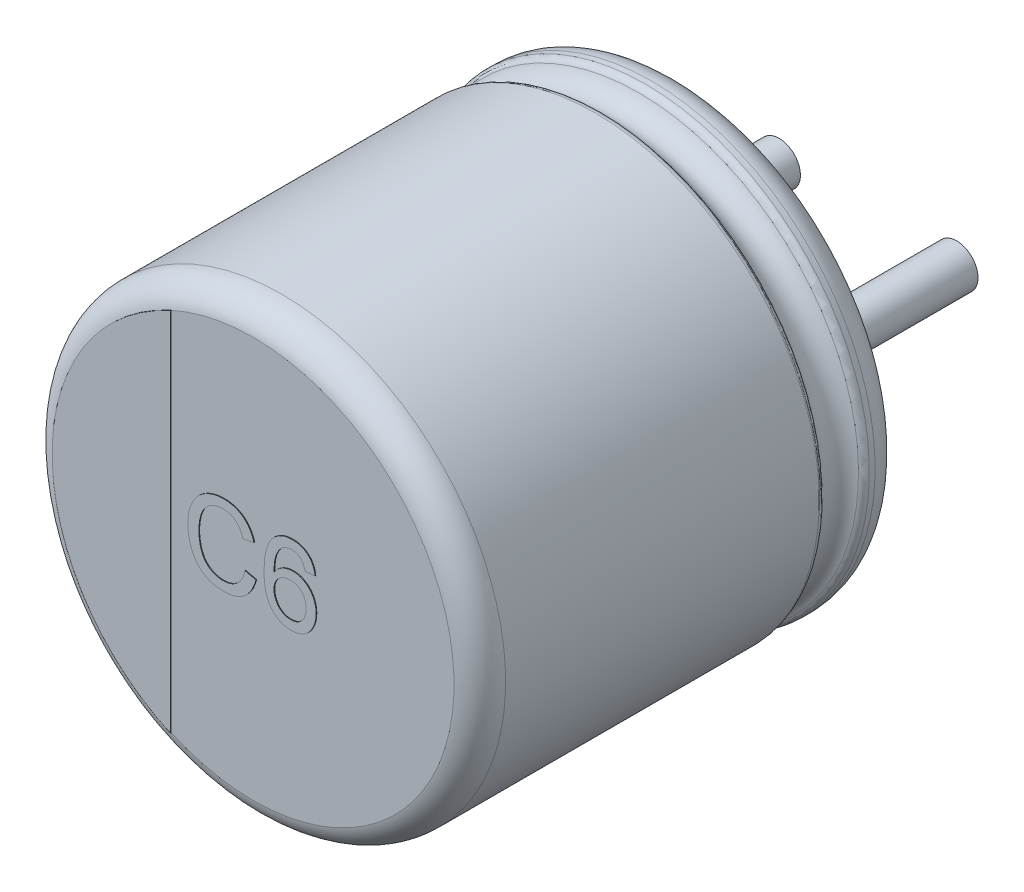
from build123d import *

# Parameters (mm, degrees)
SKETCH_2_R         = 0.3
EXTRUDE_1_DEPTH    = 2.7
EXTRUDE_2_DEPTH    = 0.01
EXTRUDE_1853_DEPTH = 0.01
EXTRUDE_5_DEPTH    = 0.05


with BuildPart() as part:
    # Sketch10 → Повернуть1 (revolve)
    with BuildSketch(Plane(origin=(0, 0, 0), x_dir=(0, 0, -1), z_dir=(1, 0, 0))):
        with BuildLine():
            Line((-6, 0), (-0.05, 0))
            Line((-0.05, 0), (-0.05, 2.553143426))
            ThreePointArc((-0.05, 2.553143426), (-0.052704561, 2.951565585), (-0.398206102, 3.15))
            Line((-0.398206102, 3.15), (-0.479422929, 3.15))
            ThreePointArc((-0.479422929, 3.15), (-0.534479696, 3.133479053), (-0.571344666, 3.089375046))
            ThreePointArc((-0.571344666, 3.089375046), (-0.831990181, 2.917472047), (-1.092635697, 3.089375046))
            ThreePointArc((-1.092635697, 3.089375046), (-1.129500666, 3.133479053), (-1.184557434, 3.15))
            Line((-1.184557434, 3.15), (-5.6, 3.15))
            ThreePointArc((-5.6, 3.15), (-5.85971595, 3.059961924), (-6, 2.82357323))
            Line((-6, 2.82357323), (-6, 0))
        make_face()
    revolve(axis=Axis((0, 0, -18.1630778), (0, 0, 1)))

    # Эскиз2 → Бобышка-Вытянуть1 (add)
    with BuildSketch(Plane(origin=(0, 0, 0.05), x_dir=(-1, 0, 0), z_dir=(0, 0, -1))):
        with Locations(Location((-1.25, 0, 0), (0, 0, 90))):
            Circle(SKETCH_2_R)
        with Locations(Location((1.25, 0, 0), (0, 0, 270))):
            Circle(SKETCH_2_R)
    extrude(amount=EXTRUDE_1_DEPTH)

    # Эскиз4 → Бобышка-Вытянуть2 (add)
    with BuildSketch(Plane.XY.offset(6)):
        with BuildLine():
            Line((-1.160332513, -2.574139515), (-1.160332513, 2.574139515))
            ThreePointArc((-1.160332513, 2.574139515), (-2.82357323, 0), (-1.160332513, -2.574139515))
        make_face()
    extrude(amount=EXTRUDE_2_DEPTH)

    # Эскиз5 → Extrude 1853 (add)
    with BuildSketch(Plane.XY.offset(6)):
        with BuildLine():
            Line((-0.108912855, -0.069918347), (0.04621535, -0.106056167))
            add(Edge.make_bspline(
                [(0.04621535, -0.106056167), (0.042328955, -0.120595903), (0.034726685, -0.149037431), (0.019696074, -0.189740405), (0.002826055, -0.22793841), (-0.016292712, -0.263530826), (-0.037869483, -0.296313018), (-0.061332559, -0.326706301), (-0.08761128, -0.354073299), (-0.115741448, -0.379045627), (-0.145942088, -0.401071154), (-0.177849082, -0.420090601), (-0.2113082, -0.436272289), (-0.246454673, -0.449579116), (-0.283311287, -0.459593644), (-0.321688266, -0.466892819), (-0.361697515, -0.471388685), (-0.388969191, -0.471980579), (-0.402863176, -0.472282129)],
                knots=[0, 0, 0, 0, 1.145254194, 2.240259345, 3.299159039, 4.322497661, 5.312016644, 6.284080175, 7.241264552, 8.196044782, 9.144516039, 10.082428046, 11.020306713, 11.970622414, 12.939253955, 13.924100776, 14.94240044, 16, 16, 16, 16], degree=3))
            add(Edge.make_bspline(
                [(-0.402863176, -0.472282129), (-0.417118674, -0.472075022), (-0.445008416, -0.471669834), (-0.48586528, -0.468374144), (-0.524724169, -0.462658281), (-0.561512517, -0.454716909), (-0.596354147, -0.444897895), (-0.629104581, -0.432544706), (-0.659706455, -0.417746474), (-0.68841503, -0.40091706), (-0.715108371, -0.381798088), (-0.740393493, -0.360905526), (-0.763656558, -0.337664227), (-0.785479231, -0.312622937), (-0.805386205, -0.285451329), (-0.824109863, -0.25651854), (-0.840736314, -0.225314775), (-0.855881721, -0.192418552), (-0.869175168, -0.158148367), (-0.880935219, -0.12318115), (-0.890549703, -0.087447226), (-0.898827154, -0.051247288), (-0.904840321, -0.01427674), (-0.90961459, 0.023187027), (-0.912239578, 0.061373697), (-0.912584999, 0.087042498), (-0.912759009, 0.09997348)],
                knots=[0, 0, 0, 0, 1.180702053, 2.309949215, 3.392367133, 4.431746864, 5.425408375, 6.388154007, 7.326956194, 8.237882283, 9.141054626, 10.043899035, 10.951650021, 11.86168169, 12.792564695, 13.739356664, 14.713891418, 15.718426911, 16.737522708, 17.757217648, 18.772674716, 19.801476837, 20.831699174, 21.873853055, 22.928926693, 24, 24, 24, 24], degree=3))
            add(Edge.make_bspline(
                [(-0.912759009, 0.09997348), (-0.912510138, 0.113932996), (-0.912018432, 0.141513475), (-0.909242757, 0.182209272), (-0.904144849, 0.221485694), (-0.897065337, 0.259368577), (-0.888106922, 0.295888601), (-0.877048763, 0.331063557), (-0.864030746, 0.364848441), (-0.849092557, 0.397280506), (-0.83213495, 0.427997725), (-0.81366404, 0.457043765), (-0.793239225, 0.483941703), (-0.771466071, 0.509205432), (-0.747800778, 0.532414283), (-0.72231561, 0.553620827), (-0.695230442, 0.573018497), (-0.666549228, 0.590427213), (-0.636646863, 0.605702449), (-0.605967495, 0.619308236), (-0.574389099, 0.630460027), (-0.542162036, 0.639732294), (-0.509216926, 0.647113879), (-0.475476789, 0.652049968), (-0.4409728, 0.655266706), (-0.417707516, 0.655702651), (-0.405948112, 0.655922999)],
                knots=[0, 0, 0, 0, 1.185634383, 2.342514083, 3.462112933, 4.547331452, 5.613960142, 6.653690668, 7.676612054, 8.686959706, 9.683658101, 10.654407272, 11.607580201, 12.5494388, 13.484601218, 14.419076806, 15.362504069, 16.311442244, 17.265594461, 18.212500624, 19.159571152, 20.107257795, 21.059246075, 22.024387127, 23.001429356, 24, 24, 24, 24], degree=3))
            add(Edge.make_bspline(
                [(-0.405948112, 0.655922999), (-0.392790923, 0.655674993), (-0.366929166, 0.655187511), (-0.328981645, 0.651177881), (-0.292637827, 0.64446219), (-0.25774023, 0.635651838), (-0.224651675, 0.623588633), (-0.19301293, 0.609246868), (-0.163138738, 0.592016975), (-0.134796652, 0.572372462), (-0.108448038, 0.5502771), (-0.083724175, 0.526258741), (-0.061633171, 0.499717103), (-0.04130009, 0.471294538), (-0.023364678, 0.440596924), (-0.007167108, 0.407891911), (0.006762331, 0.372936375), (0.014215274, 0.348588877), (0.018010222, 0.336191429)],
                knots=[0, 0, 0, 0, 1.098391872, 2.158997981, 3.181470371, 4.182549255, 5.160268219, 6.118029851, 7.079534476, 8.035645336, 8.993622929, 9.94770573, 10.909620999, 11.872786677, 12.862530088, 13.874594564, 14.917769567, 16, 16, 16, 16], degree=3))
            Line((0.018010222, 0.336191429), (-0.137117984, 0.302918192))
            add(Edge.make_bspline(
                [(-0.137117984, 0.302918192), (-0.140164459, 0.312432596), (-0.146127355, 0.331055231), (-0.15671506, 0.357595794), (-0.168149428, 0.382234108), (-0.180702836, 0.404802692), (-0.194402488, 0.425306953), (-0.20893292, 0.443996089), (-0.224642265, 0.460521265), (-0.241210981, 0.47526351), (-0.259066923, 0.487822492), (-0.277791469, 0.498951816), (-0.297779426, 0.508159635), (-0.318743252, 0.515947548), (-0.340878894, 0.521874989), (-0.364096214, 0.526045177), (-0.388415609, 0.528458678), (-0.404987911, 0.528817113), (-0.413440099, 0.528999922)],
                knots=[0, 0, 0, 0, 1.235697765, 2.418642872, 3.532555292, 4.594392283, 5.610119701, 6.580908344, 7.519430642, 8.427315627, 9.319973334, 10.216139639, 11.118687699, 12.038725643, 12.980015607, 13.949697744, 14.954307006, 16, 16, 16, 16], degree=3))
            add(Edge.make_bspline(
                [(-0.413440099, 0.528999922), (-0.423143984, 0.528859129), (-0.442228662, 0.528582229), (-0.47026635, 0.525551592), (-0.497192283, 0.52108776), (-0.522805782, 0.51439386), (-0.547247006, 0.506048307), (-0.570370917, 0.495656617), (-0.592374217, 0.483476338), (-0.613011338, 0.469434324), (-0.632108844, 0.453648399), (-0.650184985, 0.436960206), (-0.666371907, 0.418591447), (-0.681286864, 0.399147811), (-0.694495535, 0.378285716), (-0.706385552, 0.356289328), (-0.716881124, 0.332978371), (-0.72832201, 0.300169965), (-0.739987527, 0.257913496), (-0.750107378, 0.206205274), (-0.756553484, 0.153682392), (-0.757270938, 0.118354545), (-0.757630804, 0.100634538)],
                knots=[0, 0, 0, 0, 0.935256702, 1.839373932, 2.716087708, 3.564631604, 4.388828665, 5.203538865, 6.005592122, 6.810952829, 7.606223804, 8.392839071, 9.180346482, 9.963639178, 10.753404291, 11.558266631, 12.372976832, 13.215232055, 14.905983541, 16.594894834, 18.292041732, 20, 20, 20, 20], degree=3))
            add(Edge.make_bspline(
                [(-0.757630804, 0.100634538), (-0.757224926, 0.078354594), (-0.756437487, 0.035129485), (-0.748667393, -0.027510838), (-0.73682082, -0.085937398), (-0.722523713, -0.131521756), (-0.708182278, -0.165145637), (-0.696583647, -0.188692925), (-0.683344271, -0.210482444), (-0.668793463, -0.230637938), (-0.652743794, -0.249100614), (-0.635418867, -0.265968548), (-0.616814812, -0.281404048), (-0.59671119, -0.29468455), (-0.575881813, -0.306476479), (-0.554589531, -0.316962087), (-0.53282094, -0.32583035), (-0.51048821, -0.332719396), (-0.487904955, -0.338672491), (-0.464822442, -0.342561331), (-0.441247254, -0.34475607), (-0.425417098, -0.345156447), (-0.417406445, -0.345359052)],
                knots=[0, 0, 0, 0, 2.10686522, 4.087509323, 5.961373225, 7.741398778, 8.594514555, 9.418024779, 10.222433421, 11.003575649, 11.767087398, 12.533660211, 13.289033706, 14.050297079, 14.809623433, 15.552362432, 16.294320901, 17.0305302, 17.761969017, 18.502233515, 19.242073914, 20, 20, 20, 20], degree=3))
            add(Edge.make_bspline(
                [(-0.417406445, -0.345359052), (-0.407846827, -0.345158567), (-0.388963202, -0.344762537), (-0.361277409, -0.34129607), (-0.334588687, -0.336187777), (-0.309220365, -0.328305166), (-0.284831211, -0.318653832), (-0.261621051, -0.306752049), (-0.239662879, -0.292437677), (-0.218698419, -0.276185053), (-0.199114272, -0.257692345), (-0.181166455, -0.237108537), (-0.165065235, -0.214339793), (-0.150135352, -0.189751516), (-0.137591507, -0.162609165), (-0.125972944, -0.133721734), (-0.116291518, -0.102614431), (-0.111407741, -0.080973603), (-0.108912855, -0.069918347)],
                knots=[0, 0, 0, 0, 1.013374089, 2.001772144, 2.95501459, 3.891367103, 4.814208647, 5.733921849, 6.652182523, 7.590185968, 8.54346024, 9.504121027, 10.481158517, 11.497760682, 12.549996529, 13.647863555, 14.798406869, 16, 16, 16, 16], degree=3))
        make_face()
        with BuildLine():
            Line((0.878266632, 0.359769153), (0.737240991, 0.345666589))
            add(Edge.make_bspline(
                [(0.737240991, 0.345666589), (0.734197771, 0.357795547), (0.728469378, 0.380626442), (0.716456991, 0.411593108), (0.703219597, 0.437785641), (0.691719179, 0.451889596), (0.686339548, 0.458487102)],
                knots=[0, 0, 0, 0, 1.199207122, 2.257322842, 3.184815751, 4, 4, 4, 4], degree=3))
            add(Edge.make_bspline(
                [(0.686339548, 0.458487102), (0.681721761, 0.462986963), (0.672639642, 0.471837148), (0.657730109, 0.483373428), (0.642012993, 0.493147542), (0.62544079, 0.501066057), (0.608103032, 0.507321229), (0.589927902, 0.511697055), (0.570956574, 0.51440594), (0.558029983, 0.514732157), (0.551483779, 0.514897358)],
                knots=[0, 0, 0, 0, 1.028360939, 2.022547923, 3.001693811, 3.976902288, 4.948369586, 5.937776631, 6.955661634, 8, 8, 8, 8], degree=3))
            add(Edge.make_bspline(
                [(0.551483779, 0.514897358), (0.540871256, 0.514555648), (0.519901374, 0.513880444), (0.48913481, 0.507270246), (0.459251827, 0.497377031), (0.440738215, 0.487348218), (0.431391632, 0.482285179)],
                knots=[0, 0, 0, 0, 1.010336883, 1.996381556, 2.988474728, 4, 4, 4, 4], degree=3))
            add(Edge.make_bspline(
                [(0.431391632, 0.482285179), (0.422199847, 0.474669548), (0.403331312, 0.459036479), (0.378707641, 0.430149843), (0.356687017, 0.396517172), (0.34044641, 0.365118512), (0.329016787, 0.336966852), (0.321624728, 0.312840023), (0.315309134, 0.286184842), (0.310047887, 0.25705153), (0.305978651, 0.225416456), (0.302577585, 0.191259529), (0.300696507, 0.154494143), (0.300277541, 0.129135316), (0.300061504, 0.116059217)],
                knots=[0, 0, 0, 0, 1.063306303, 2.18271343, 3.369442992, 4.644240368, 5.329284104, 6.077448525, 6.892756613, 7.771869145, 8.717113863, 9.73749892, 10.833357348, 12, 12, 12, 12], degree=3))
            add(Edge.make_bspline(
                [(0.300061504, 0.116059217), (0.308375901, 0.127740696), (0.32465184, 0.150607904), (0.353363827, 0.180519908), (0.384715991, 0.205805044), (0.418743384, 0.225993532), (0.454558126, 0.24164011), (0.491370458, 0.25289923), (0.529115862, 0.259810377), (0.55453993, 0.260635492), (0.567349164, 0.261051204)],
                knots=[0, 0, 0, 0, 1.083917396, 2.121834425, 3.126226247, 4.123362703, 5.106535049, 6.077135049, 7.031216202, 8, 8, 8, 8], degree=3))
            add(Edge.make_bspline(
                [(0.567349164, 0.261051204), (0.578381053, 0.260754389), (0.600176647, 0.260167973), (0.632273128, 0.255520903), (0.663044191, 0.247392857), (0.692756502, 0.236804211), (0.720839084, 0.222346504), (0.747977313, 0.205449702), (0.773542664, 0.184888233), (0.797858696, 0.161785079), (0.819997496, 0.136099509), (0.839591905, 0.108454522), (0.855920624, 0.078783856), (0.869161328, 0.047286217), (0.879524491, 0.01407622), (0.887054561, -0.020940442), (0.891462563, -0.057832979), (0.892062936, -0.083054194), (0.892369196, -0.095919949)],
                knots=[0, 0, 0, 0, 0.981553735, 1.939246043, 2.877808487, 3.810434071, 4.740031046, 5.683044261, 6.650811044, 7.654063953, 8.664382933, 9.663624521, 10.66421212, 11.671863278, 12.699354266, 13.755775259, 14.855184124, 16, 16, 16, 16], degree=3))
            add(Edge.make_bspline(
                [(0.892369196, -0.095919949), (0.891820487, -0.112923039), (0.890737622, -0.146478227), (0.882045939, -0.195892728), (0.868040584, -0.24352353), (0.851286634, -0.281242997), (0.835894127, -0.310140139), (0.822824089, -0.330352082), (0.808848531, -0.349346216), (0.794232176, -0.367383916), (0.777914888, -0.383639628), (0.760885915, -0.39887931), (0.742582384, -0.412576086), (0.723542623, -0.425185692), (0.703406957, -0.436119507), (0.68276128, -0.445835384), (0.66143564, -0.454111523), (0.639361177, -0.46060969), (0.616650946, -0.465985755), (0.593229358, -0.469682296), (0.569158055, -0.471962046), (0.552884495, -0.472174609), (0.54465285, -0.472282129)],
                knots=[0, 0, 0, 0, 1.777979151, 3.508799182, 5.232661887, 6.960203328, 7.816385973, 8.656273476, 9.47551652, 10.283326439, 11.082130802, 11.882412381, 12.672407567, 13.471692325, 14.269609044, 15.067192643, 15.857822979, 16.66013129, 17.472860815, 18.297850482, 19.139002666, 20, 20, 20, 20], degree=3))
            add(Edge.make_bspline(
                [(0.54465285, -0.472282129), (0.53075114, -0.471896627), (0.503487444, -0.47114059), (0.463583035, -0.465332373), (0.425692055, -0.455626025), (0.389733901, -0.442055454), (0.355599034, -0.424922886), (0.323623847, -0.403446031), (0.293631411, -0.378261711), (0.265598604, -0.349223866), (0.240181283, -0.315693889), (0.218458495, -0.276990007), (0.199948751, -0.233451013), (0.184800137, -0.184957116), (0.173337009, -0.131457605), (0.165083074, -0.07306738), (0.160006995, -0.009778077), (0.159367141, 0.034078194), (0.159035863, 0.056784378)],
                knots=[0, 0, 0, 0, 0.898506621, 1.76212948, 2.600594211, 3.422599815, 4.24233914, 5.064166416, 5.906856258, 6.769969817, 7.668413694, 8.619051846, 9.63165591, 10.722000005, 11.898403521, 13.164960021, 14.532183992, 16, 16, 16, 16], degree=3))
            add(Edge.make_bspline(
                [(0.159035863, 0.056784378), (0.159090793, 0.06971401), (0.159199135, 0.095215666), (0.160940093, 0.132747746), (0.162937188, 0.168994042), (0.166358893, 0.203809947), (0.17039903, 0.237352051), (0.175820839, 0.269423104), (0.18164321, 0.300272384), (0.188722024, 0.329657007), (0.196613171, 0.357853407), (0.205696155, 0.384551765), (0.215290037, 0.410097512), (0.226174097, 0.434087664), (0.237773969, 0.456912938), (0.250595929, 0.478150947), (0.264042682, 0.498287303), (0.273969634, 0.510704012), (0.278907657, 0.516880531)],
                knots=[0, 0, 0, 0, 1.28053818, 2.525659045, 3.721026795, 4.875695215, 5.990149104, 7.066600796, 8.096771069, 9.099076143, 10.059445332, 10.995815448, 11.891625124, 12.761078582, 13.603822678, 14.426062074, 15.217066536, 16, 16, 16, 16], degree=3))
            add(Edge.make_bspline(
                [(0.278907657, 0.516880531), (0.287791073, 0.526872624), (0.305301111, 0.546567967), (0.33525528, 0.572009685), (0.36717397, 0.593740826), (0.401566246, 0.611297707), (0.438169246, 0.624985615), (0.477005916, 0.634921823), (0.518184629, 0.640684138), (0.546324023, 0.64143553), (0.560738587, 0.641820435)],
                knots=[0, 0, 0, 0, 1.005002357, 1.980952959, 2.948226316, 3.90482984, 4.879026092, 5.883055346, 6.915583142, 8, 8, 8, 8], degree=3))
            add(Edge.make_bspline(
                [(0.560738587, 0.641820435), (0.57147183, 0.641630705), (0.59255815, 0.641257964), (0.623454992, 0.637681476), (0.652843318, 0.631703913), (0.680788583, 0.623640849), (0.707128293, 0.612907881), (0.732166114, 0.600188152), (0.755647807, 0.584887118), (0.777403376, 0.567213824), (0.797486709, 0.547669261), (0.815475071, 0.526089303), (0.831300683, 0.502742909), (0.845087303, 0.477581526), (0.856711736, 0.450724258), (0.866255973, 0.422055677), (0.87351023, 0.39158315), (0.876659188, 0.370520814), (0.878266632, 0.359769153)],
                knots=[0, 0, 0, 0, 1.095988384, 2.15315746, 3.171326302, 4.156539379, 5.119213808, 6.072133135, 7.021027441, 7.975952916, 8.930907862, 9.879001051, 10.840359051, 11.807350428, 12.805278655, 13.825435679, 14.889953203, 16, 16, 16, 16], degree=3))
        make_face()
        with BuildLine():
            add(Edge.make_bspline(
                [(0.300061504, -0.093055366), (0.300453761, -0.10409761), (0.301233126, -0.126037133), (0.307194378, -0.158602592), (0.316929524, -0.190376134), (0.330271652, -0.221004885), (0.346746723, -0.249462101), (0.366315267, -0.274677159), (0.38855253, -0.296279838), (0.413339003, -0.314317016), (0.440616506, -0.32817809), (0.469896492, -0.338217111), (0.501213942, -0.344284728), (0.522810685, -0.344995535), (0.533855574, -0.345359052)],
                knots=[0, 0, 0, 0, 1.034121613, 2.054667162, 3.090870403, 4.141799978, 5.178094622, 6.163726224, 7.122467907, 8.07367165, 9.024701118, 9.977919151, 10.965878387, 12, 12, 12, 12], degree=3))
            add(Edge.make_bspline(
                [(0.533855574, -0.345359052), (0.541726313, -0.345146188), (0.5570893, -0.344730697), (0.579583208, -0.341511055), (0.601044882, -0.336560203), (0.621350052, -0.329245354), (0.640471163, -0.319909594), (0.658507497, -0.308547361), (0.675447391, -0.295124638), (0.691086026, -0.279666064), (0.70521997, -0.26247335), (0.717500492, -0.243652001), (0.728345341, -0.223511677), (0.736502399, -0.201557436), (0.74314922, -0.178351725), (0.748035902, -0.153675127), (0.750904899, -0.127499308), (0.751195219, -0.109515607), (0.751343555, -0.100327001)],
                knots=[0, 0, 0, 0, 1.023436885, 1.997658284, 2.950132304, 3.883974581, 4.798406504, 5.712938251, 6.651509614, 7.604127386, 8.56812849, 9.540661787, 10.523651728, 11.536824179, 12.580180944, 13.661349568, 14.805088061, 16, 16, 16, 16], degree=3))
            add(Edge.make_bspline(
                [(0.751343555, -0.100327001), (0.751205975, -0.091503315), (0.750936921, -0.074247485), (0.7479095, -0.049067562), (0.743499274, -0.025263608), (0.736729066, -0.003035916), (0.728419794, 0.01785083), (0.718008367, 0.037240392), (0.705877087, 0.055297562), (0.691653661, 0.071544196), (0.676099327, 0.086345835), (0.659016551, 0.099202471), (0.64061035, 0.110060597), (0.620814323, 0.118949804), (0.599591181, 0.125762335), (0.576984871, 0.130483585), (0.553122592, 0.133779223), (0.536731966, 0.134010043), (0.52834676, 0.134128128)],
                knots=[0, 0, 0, 0, 1.155658139, 2.260035327, 3.319019312, 4.323913291, 5.299809325, 6.260058621, 7.202437855, 8.144128683, 9.083751266, 10.011616631, 10.939332216, 11.87851101, 12.849505762, 13.853846437, 14.90205895, 16, 16, 16, 16], degree=3))
            add(Edge.make_bspline(
                [(0.52834676, 0.134128128), (0.520548506, 0.134006285), (0.505181306, 0.133766184), (0.482645177, 0.13044483), (0.460924923, 0.125714118), (0.440107268, 0.118831598), (0.420185048, 0.109968224), (0.401162682, 0.099186981), (0.383205359, 0.086179019), (0.366149341, 0.071611599), (0.350585931, 0.055429204), (0.336931316, 0.037921777), (0.325794041, 0.018976683), (0.316058254, -0.000942602), (0.308925183, -0.022305635), (0.303849912, -0.044826003), (0.300703374, -0.068507864), (0.300278789, -0.084745559), (0.300061504, -0.093055366)],
                knots=[0, 0, 0, 0, 1.036988316, 2.04348404, 3.025371103, 3.992992706, 4.955812186, 5.923433788, 6.897355974, 7.902569022, 8.905116476, 9.880852345, 10.849905012, 11.825004025, 12.826645469, 13.839294292, 14.894236693, 16, 16, 16, 16], degree=3))
        make_face(mode=Mode.SUBTRACT)
    extrude(amount=EXTRUDE_1853_DEPTH)

    # Эскиз6 → Бобышка-Вытянуть5 (add)
    with BuildSketch(Plane(origin=(0, 0, 0.05), x_dir=(-1, 0, 0), z_dir=(0, 0, -1))):
        with BuildLine():
            Line((-1.25, 0.4), (-1.624807681, 0.4))
            ThreePointArc((-1.624807681, 0.4), (-1.831827349, 0.509847022), (-1.856923064, 0.742857143))
            ThreePointArc((-1.856923064, 0.742857143), (0, 2), (1.856923064, 0.742857143))
            ThreePointArc((1.856923064, 0.742857143), (1.831827349, 0.509847022), (1.624807681, 0.4))
            Line((1.624807681, 0.4), (1.25, 0.4))
            ThreePointArc((1.25, 0.4), (0.85, 0), (1.25, -0.4))
            Line((1.25, -0.4), (1.624807681, -0.4))
            ThreePointArc((1.624807681, -0.4), (1.831827349, -0.509847022), (1.856923064, -0.742857143))
            ThreePointArc((1.856923064, -0.742857143), (0, -2), (-1.856923064, -0.742857143))
            ThreePointArc((-1.856923064, -0.742857143), (-1.831827349, -0.509847022), (-1.624807681, -0.4))
            Line((-1.624807681, -0.4), (-1.25, -0.4))
            ThreePointArc((-1.25, -0.4), (-0.85, 0), (-1.25, 0.4))
        make_face()
    extrude(amount=EXTRUDE_5_DEPTH)


solid = part.part
